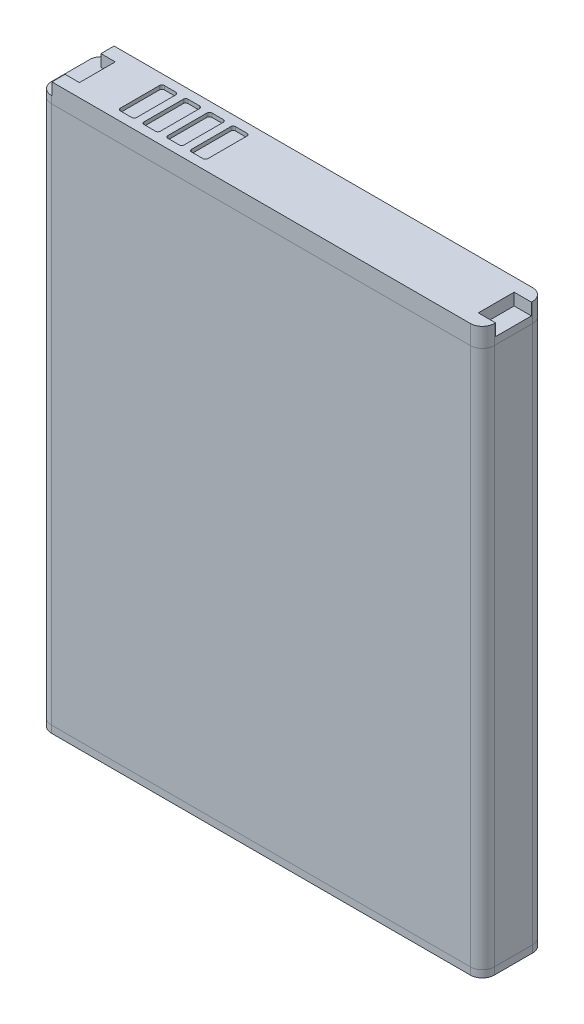
from build123d import *

# Parameters (mm, degrees)
SKETCH1_W           = 46.3
SKETCH1_H           = 6.5
BOSS_EXTRUDE1_DEPTH = 59
FILLET1_R           = 1.25
SKETCH2_W           = 1.8
SKETCH2_H           = 3.75
CUT_EXTRUDE1_DEPTH  = 1.25
SKETCH3_W           = 1.7
SKETCH3_H           = 4.6
CUT_EXTRUDE2_DEPTH  = 0.4
FILLET2_R           = 0.25


with BuildPart() as part:
    # Sketch1 → Boss-Extrude1 (new body)
    with BuildSketch(Plane(origin=(0, 0, 0), x_dir=(1, 0, 0), z_dir=(0, 1, 0))):
        Rectangle(SKETCH1_W, SKETCH1_H)
    extrude(amount=BOSS_EXTRUDE1_DEPTH)

    # Fillet1
    fillet1_edges = [part.edges().sort_by_distance(p)[0] for p in [
        (23.15, 29.5, 3.25),
        (-23.15, 29.5, 3.25),
        (-23.15, 29.5, -3.25),
        (23.15, 29.5, -3.25),
    ]]
    fillet(fillet1_edges, radius=FILLET1_R)

    # Sketch2 → Cut-Extrude1 (cut)
    with BuildSketch(Plane(origin=(0, 59, 0), x_dir=(1, 0, 0), z_dir=(0, 1, 0))):
        with Locations((22.25, 0)):
            Rectangle(SKETCH2_W, SKETCH2_H)
        with BuildLine():
            Line((-21.85, 3.25), (-21.85, 1.875))
            Line((-21.85, 1.875), (-20.35, 1.875))
            Line((-20.35, 1.875), (-20.35, 0))
            Line((-20.35, 0), (-20.35, -1.875))
            Line((-20.35, -1.875), (-21.85, -1.875))
            Line((-21.85, -1.875), (-21.85, -3.25))
            Line((-21.85, -3.25), (-21.9, -3.25))
            ThreePointArc((-21.9, -3.25), (-22.783883476, -2.883883476), (-23.15, -2))
            Line((-23.15, -2), (-23.15, 2))
            ThreePointArc((-23.15, 2), (-22.783883476, 2.883883476), (-21.9, 3.25))
            Line((-21.9, 3.25), (-21.85, 3.25))
        make_face()
    extrude(amount=-CUT_EXTRUDE1_DEPTH, mode=Mode.SUBTRACT)

    # Sketch3 → Cut-Extrude2 (cut)
    with BuildSketch(Plane(origin=(0, 59, 0), x_dir=(1, 0, 0), z_dir=(0, 1, 0))):
        with Locations((-15.05, 0)):
            Rectangle(SKETCH3_W, SKETCH3_H)
        with Locations((-12.566666667, 0)):
            Rectangle(SKETCH3_W, SKETCH3_H)
        with Locations((-10.083333333, 0)):
            Rectangle(SKETCH3_W, SKETCH3_H)
        with Locations((-7.6, 0)):
            Rectangle(SKETCH3_W, SKETCH3_H)
    extrude(amount=-CUT_EXTRUDE2_DEPTH, mode=Mode.SUBTRACT)

    # Fillet2
    fillet2_edges = [part.edges().sort_by_distance(p)[0] for p in [
        (-13.416666667, 58.8, -2.3),
        (-11.716666667, 58.8, -2.3),
        (-11.716666667, 58.8, 2.3),
        (-13.416666667, 58.8, 2.3),
        (-10.933333333, 58.8, -2.3),
        (-9.233333333, 58.8, -2.3),
        (-9.233333333, 58.8, 2.3),
        (-10.933333333, 58.8, 2.3),
        (-8.45, 58.8, -2.3),
        (-6.75, 58.8, -2.3),
        (-6.75, 58.8, 2.3),
        (-8.45, 58.8, 2.3),
        (-14.2, 58.8, -2.3),
        (-14.2, 58.8, 2.3),
        (-15.9, 58.8, 2.3),
        (-15.9, 58.8, -2.3),
    ]]
    fillet(fillet2_edges, radius=FILLET2_R)


solid = part.part
